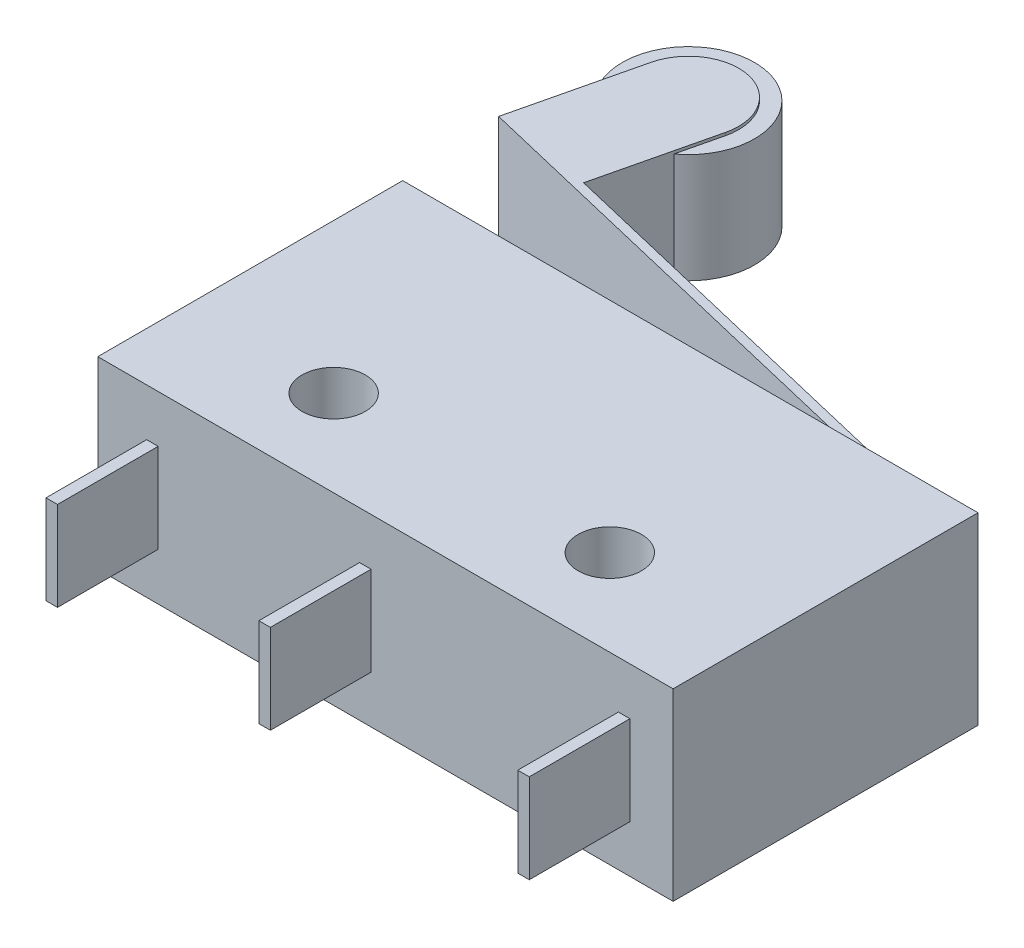
from build123d import *

# Parameters (mm, degrees)
SKETCH_1_W      = 20
SKETCH_1_H      = 10.6
SKETCH_1_R      = 1.1
EXTRUDE_1_DEPTH = 3.2
SKETCH_3_W      = 0.4
SKETCH_3_H      = 3.1
EXTRUDE_2_DEPTH = 3.5
EXTRUDE_3_DEPTH = 2
SKETCH_5_R      = 2.3
EXTRUDE_4_DEPTH = 1.9


with BuildPart() as part:
    # 草图1 → 凸台-拉伸1 (new body, symmetric)
    with BuildSketch(Plane(origin=(0, 0, 0), x_dir=(1, 0, 0), z_dir=(0, 1, 0))):
        Rectangle(SKETCH_1_W, SKETCH_1_H)
        with Locations((-4.8, -2.3)):
            Circle(SKETCH_1_R, mode=Mode.SUBTRACT)
        with Locations((4.8, -2.3)):
            Circle(SKETCH_1_R, mode=Mode.SUBTRACT)
    extrude(amount=EXTRUDE_1_DEPTH, both=True)

    # 草图3 → 凸台-拉伸2 (add)
    with BuildSketch(Plane.XY.offset(5.3)):
        with Locations((-8.1, 0)):
            Rectangle(SKETCH_3_W, SKETCH_3_H)
        with Locations((-0.7, 0)):
            Rectangle(SKETCH_3_W, SKETCH_3_H)
        with Locations((8.3, 0)):
            Rectangle(SKETCH_3_W, SKETCH_3_H)
    extrude(amount=EXTRUDE_2_DEPTH)

    # 草图4 → 凸台-拉伸3 (add, symmetric)
    with BuildSketch(Plane(origin=(0, 0, 0), x_dir=(1, 0, 0), z_dir=(0, 1, 0))):
        with BuildLine():
            Line((6.3, 4.662469082), (6.3, 5.863134893))
            Line((6.3, 5.863134893), (-11.464883061, 10.1))
            Line((-11.464883061, 10.1), (-10.444126954, 14.379959926))
            ThreePointArc((-10.444126954, 14.379959926), (-8.335887623, 15.676234173), (-7.039613376, 13.567994841))
            Line((-7.039613376, 13.567994841), (-7.990772476, 9.579850364))
            Line((-7.990772476, 9.579850364), (6.6, 6.1))
            Line((6.6, 6.1), (6.6, 4.662469082))
            Line((6.6, 4.662469082), (6.3, 4.662469082))
        make_face()
    extrude(amount=EXTRUDE_3_DEPTH, both=True)

    # 草图5 → 凸台-拉伸4 (add, symmetric)
    with BuildSketch(Plane(origin=(0, 0, 0), x_dir=(1, 0, 0), z_dir=(0, 1, 0))):
        with Locations((-8.741870165, 13.973977384)):
            Circle(SKETCH_5_R)
    extrude(amount=EXTRUDE_4_DEPTH, both=True)


solid = part.part
